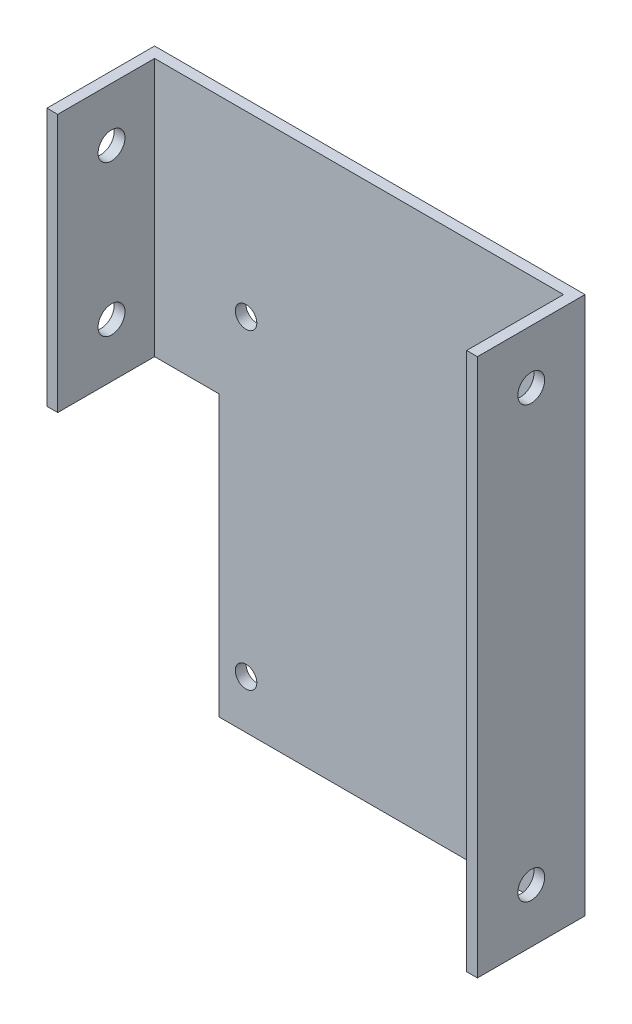
from build123d import *

# Parameters (mm, degrees)
SKETCH1_W            = 40
SKETCH1_H            = 50
BOSS_EXTRUDE1_DEPTH  = 1
SKETCH2_W            = 5
SKETCH2_H            = 25
CUT_EXTRUDE1_DEPTH   = 1
SKETCH3_W            = 1
SKETCH3_H            = 25
BOSS_EXTRUDE2_DEPTH  = 10
SKETCH4_R            = 1.25
CUT_EXTRUDE3_DEPTH   = 63
SKETCH5_R            = 1.25
BOSS_EXTRUDE3_DEPTH  = 1
SKETCH6_W            = 40
SKETCH6_H            = 10
CUT_EXTRUDE4_DEPTH   = 9
SKETCH7_R            = 1.25
CUT_EXTRUDE5_DEPTH   = 53
SKETCH8_W            = 2
SKETCH8_H            = 25
CUT_EXTRUDE6_DEPTH   = 53
SKETCH9_W            = 7
SKETCH9_H            = 2
CUT_EXTRUDE8_DEPTH   = 53
SKETCH10_W           = 9
SKETCH10_H           = 20.650485051
BOSS_EXTRUDE4_DEPTH  = 1
SKETCH11_R           = 1.25
CUT_EXTRUDE9_DEPTH   = 1
SKETCH12_R           = 1.25
BOSS_EXTRUDE5_DEPTH  = 1
SKETCH13_R           = 1.25
BOSS_EXTRUDE6_DEPTH  = 1
SKETCH14_W           = 7
SKETCH14_H           = 1
BOSS_EXTRUDE7_DEPTH  = 1
SKETCH15_W           = 1
SKETCH15_H           = 9
BOSS_EXTRUDE8_DEPTH  = 9
SKETCH16_R           = 1.25
CUT_EXTRUDE10_DEPTH  = 9
SKETCH17_W           = 1
SKETCH17_H           = 31.406889679
BOSS_EXTRUDE9_DEPTH  = 9
SKETCH18_R           = 1.25
CUT_EXTRUDE11_DEPTH  = 9
SKETCH19_W           = 33
SKETCH19_H           = 1
BOSS_EXTRUDE10_DEPTH = 9
SKETCH20_R           = 1.25
CUT_EXTRUDE12_DEPTH  = 9
SKETCH21_R           = 1
CUT_EXTRUDE13_DEPTH  = 10
SKETCH22_W           = 33
SKETCH22_H           = 1
CUT_EXTRUDE14_DEPTH  = 9
SKETCH23_W           = 1
SKETCH23_H           = 1
BOSS_EXTRUDE11_DEPTH = 9


with BuildPart() as part:
    # Sketch1 → Boss-Extrude1 (new body)
    with BuildSketch(Plane.XY):
        with Locations((4.242424242, -5.173160173)):
            Rectangle(SKETCH1_W, SKETCH1_H)
    extrude(amount=BOSS_EXTRUDE1_DEPTH)

    # Sketch2 → Cut-Extrude1 (cut)
    with BuildSketch(Plane.XY.offset(1)):
        with Locations((-13.257575758, -17.673160173)):
            Rectangle(SKETCH2_W, SKETCH2_H)
    extrude(amount=-CUT_EXTRUDE1_DEPTH, mode=Mode.SUBTRACT)

    # Sketch3 → Boss-Extrude2 (add)
    with BuildSketch(Plane(origin=(0, 0, 0), x_dir=(-1, 0, 0), z_dir=(0, 0, -1))):
        with Locations((15.257575758, 7.326839827)):
            Rectangle(SKETCH3_W, SKETCH3_H)
        with Locations((-23.742424242, 7.326839827)):
            Rectangle(SKETCH3_W, SKETCH3_H)
    extrude(amount=-BOSS_EXTRUDE2_DEPTH)

    # Sketch4 → Cut-Extrude3 (cut)
    with BuildSketch(Plane(origin=(24.242424242, 0, 0), x_dir=(0, 0, -1), z_dir=(1, 0, 0))):
        with Locations((-5, -0.173160173)):
            Circle(SKETCH4_R)
        with Locations((-5, 14.826839827)):
            Circle(SKETCH4_R)
    extrude(amount=-CUT_EXTRUDE3_DEPTH, mode=Mode.SUBTRACT)

    # Sketch5 → Boss-Extrude3 (add)
    with BuildSketch(Plane(origin=(24.242424242, 0, 0), x_dir=(0, 0, -1), z_dir=(1, 0, 0))):
        with Locations((-5, -0.173160173)):
            Circle(SKETCH5_R)
    extrude(amount=-BOSS_EXTRUDE3_DEPTH)

    # Sketch6 → Cut-Extrude4 (cut)
    with BuildSketch(Plane.XY.offset(10)):
        with Locations((4.242424242, -0.173160173)):
            Rectangle(SKETCH6_W, SKETCH6_H)
    extrude(amount=-CUT_EXTRUDE4_DEPTH, mode=Mode.SUBTRACT)

    # Sketch7 → Cut-Extrude5 (cut)
    with BuildSketch(Plane.ZY.offset(15.757575758)):
        with Locations((5, 9.826839827)):
            Circle(SKETCH7_R)
    extrude(amount=-CUT_EXTRUDE5_DEPTH, mode=Mode.SUBTRACT)

    # Sketch8 → Cut-Extrude6 (cut)
    with BuildSketch(Plane.XY.offset(1)):
        with Locations((-9.757575758, -17.673160173)):
            Rectangle(SKETCH8_W, SKETCH8_H)
    extrude(amount=-CUT_EXTRUDE6_DEPTH, mode=Mode.SUBTRACT)

    # Sketch9 → Cut-Extrude8 (cut)
    with BuildSketch(Plane.XY.offset(1)):
        with Locations((-12.257575758, -4.173160173)):
            Rectangle(SKETCH9_W, SKETCH9_H)
    extrude(amount=-CUT_EXTRUDE8_DEPTH, mode=Mode.SUBTRACT)

    # Sketch10 → Boss-Extrude4 (add)
    with BuildSketch(Plane(origin=(24.242424242, 0, 0), x_dir=(0, 0, -1), z_dir=(1, 0, 0))):
        with Locations((-5.5, -5.498402699)):
            Rectangle(SKETCH10_W, SKETCH10_H)
    extrude(amount=-BOSS_EXTRUDE4_DEPTH)

    # Sketch11 → Cut-Extrude9 (cut)
    with BuildSketch(Plane(origin=(24.242424242, 0, 0), x_dir=(0, 0, -1), z_dir=(1, 0, 0))):
        with Locations((-5, -10.823645224)):
            Circle(SKETCH11_R)
    extrude(amount=-CUT_EXTRUDE9_DEPTH, mode=Mode.SUBTRACT)

    # Sketch12 → Boss-Extrude5 (add)
    with BuildSketch(Plane(origin=(24.242424242, 0, 0), x_dir=(0, 0, -1), z_dir=(1, 0, 0))):
        with Locations((-5, 9.826839827)):
            Circle(SKETCH12_R)
    extrude(amount=-BOSS_EXTRUDE5_DEPTH)

    # Sketch13 → Boss-Extrude6 (add)
    with BuildSketch(Plane.ZY.offset(15.757575758)):
        with Locations((5, 9.826839827)):
            Circle(SKETCH13_R)
    extrude(amount=-BOSS_EXTRUDE6_DEPTH)

    # Sketch14 → Boss-Extrude7 (add)
    with BuildSketch(Plane.XY.offset(1)):
        with Locations((-12.257575758, -3.673160173)):
            Rectangle(SKETCH14_W, SKETCH14_H)
    extrude(amount=-BOSS_EXTRUDE7_DEPTH)

    # Sketch15 → Boss-Extrude8 (add)
    with BuildSketch(Plane.XY.offset(1)):
        with Locations((-15.257575758, 0.326839827)):
            Rectangle(SKETCH15_W, SKETCH15_H)
    extrude(amount=BOSS_EXTRUDE8_DEPTH)

    # Sketch16 → Cut-Extrude10 (cut)
    with BuildSketch(Plane.ZY.offset(15.757575758)):
        with Locations((5, 14.826839827)):
            Circle(SKETCH16_R)
        with Locations((5, 0.826839827)):
            Circle(SKETCH16_R)
    extrude(amount=-CUT_EXTRUDE10_DEPTH, mode=Mode.SUBTRACT)

    # Sketch17 → Boss-Extrude9 (add)
    with BuildSketch(Plane.XY.offset(1)):
        with Locations((23.742424242, -14.469715334)):
            Rectangle(SKETCH17_W, SKETCH17_H)
    extrude(amount=BOSS_EXTRUDE9_DEPTH)

    # Sketch18 → Cut-Extrude11 (cut)
    with BuildSketch(Plane(origin=(24.242424242, 0, 0), x_dir=(0, 0, -1), z_dir=(1, 0, 0))):
        with Locations((-5, -25.173160173)):
            Circle(SKETCH18_R)
    extrude(amount=-CUT_EXTRUDE11_DEPTH, mode=Mode.SUBTRACT)

    # Sketch19 → Boss-Extrude10 (add)
    with BuildSketch(Plane.XY.offset(1)):
        with Locations((7.742424242, -29.673160173)):
            Rectangle(SKETCH19_W, SKETCH19_H)
    extrude(amount=BOSS_EXTRUDE10_DEPTH)

    # Sketch20 → Cut-Extrude12 (cut)
    with BuildSketch(Plane.XZ.offset(30.173160173)):
        with Locations((-3.757575758, 5)):
            Circle(SKETCH20_R)
        with Locations((19.242424242, 5)):
            Circle(SKETCH20_R)
    extrude(amount=-CUT_EXTRUDE12_DEPTH, mode=Mode.SUBTRACT)

    # Sketch21 → Cut-Extrude13 (cut)
    with BuildSketch(Plane(origin=(0, 0, 0), x_dir=(-1, 0, 0), z_dir=(0, 0, -1))):
        with Locations((-21.742424242, 3.326839827)):
            Circle(SKETCH21_R)
        with Locations((6.257575758, 3.27845273)):
            Circle(SKETCH21_R)
        with Locations((6.257575758, -25.673160173)):
            Circle(SKETCH21_R)
        with Locations((-21.742424242, -25.673160173)):
            Circle(SKETCH21_R)
    extrude(amount=-CUT_EXTRUDE13_DEPTH, mode=Mode.SUBTRACT)

    # Sketch22 → Cut-Extrude14 (cut)
    with BuildSketch(Plane.XY.offset(10)):
        with Locations((7.742424242, -29.673160173)):
            Rectangle(SKETCH22_W, SKETCH22_H)
    extrude(amount=-CUT_EXTRUDE14_DEPTH, mode=Mode.SUBTRACT)

    # Sketch23 → Boss-Extrude11 (add)
    with BuildSketch(Plane.XY.offset(1)):
        with Locations((23.742424242, -29.673160173)):
            Rectangle(SKETCH23_W, SKETCH23_H)
    extrude(amount=BOSS_EXTRUDE11_DEPTH)


solid = part.part
